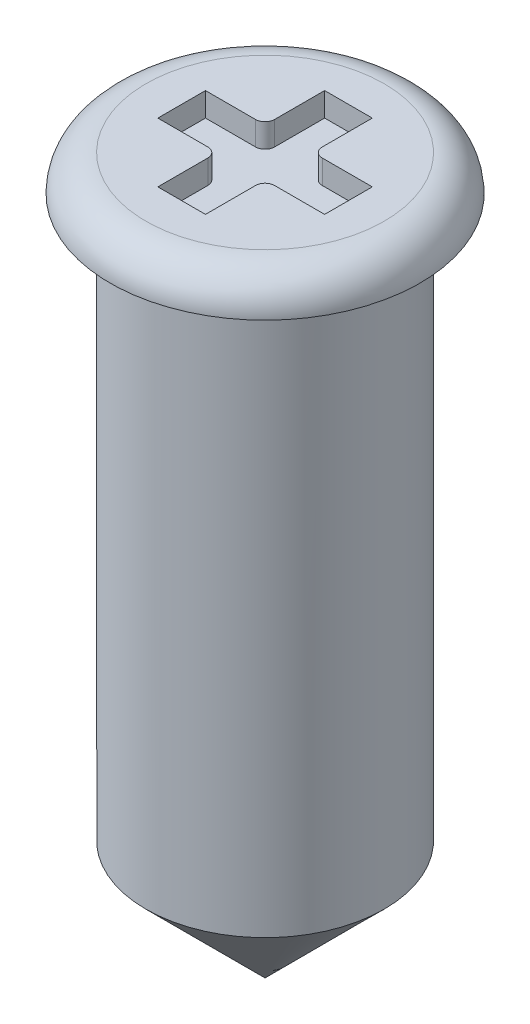
from build123d import *

# Parameters (mm, degrees)
CUT_EXTRUDE1_DEPTH = 0.1


with BuildPart() as part:
    # Sketch1 → Revolve1 (revolve)
    with BuildSketch(Plane.XY):
        with BuildLine():
            Line((0, -19.516007696), (0.5, -19.516007696))
            ThreePointArc((0.5, -19.516007696), (0.606066017, -19.559941679), (0.65, -19.666007696))
            Line((0.65, -19.666007696), (0.5, -19.666007696))
            Line((0.5, -19.666007696), (0.5, -19.816007696))
            Line((0.5, -19.816007696), (0.5, -22.016007696))
            Line((0.5, -22.016007696), (0, -22.516007696))
            Line((0, -22.516007696), (0, -19.516007696))
        make_face()
    revolve(axis=Axis((0, -22.516007696, 0), (0, 1, 0)))

    # Sketch2 → Cut-Extrude1 (cut)
    with BuildSketch(Plane(origin=(0, -19.516007696, 0), x_dir=(1, 0, 0), z_dir=(0, 1, 0))):
        with BuildLine():
            Line((-0.1, 0.35), (0.1, 0.35))
            Line((0.1, 0.35), (0.1, 0.14))
            ThreePointArc((0.1, 0.14), (0.111715729, 0.111715729), (0.14, 0.1))
            Line((0.14, 0.1), (0.35, 0.1))
            Line((0.35, 0.1), (0.35, -0.1))
            Line((0.35, -0.1), (0.14, -0.1))
            ThreePointArc((0.14, -0.1), (0.111715729, -0.111715729), (0.1, -0.14))
            Line((0.1, -0.14), (0.1, -0.35))
            Line((0.1, -0.35), (-0.1, -0.35))
            Line((-0.1, -0.35), (-0.1, -0.14))
            ThreePointArc((-0.1, -0.14), (-0.111715729, -0.111715729), (-0.14, -0.1))
            Line((-0.14, -0.1), (-0.35, -0.1))
            Line((-0.35, -0.1), (-0.35, 0.1))
            Line((-0.35, 0.1), (-0.14, 0.1))
            ThreePointArc((-0.14, 0.1), (-0.111715729, 0.111715729), (-0.1, 0.14))
            Line((-0.1, 0.14), (-0.1, 0.35))
        make_face()
    extrude(amount=-CUT_EXTRUDE1_DEPTH, mode=Mode.SUBTRACT)


solid = part.part
